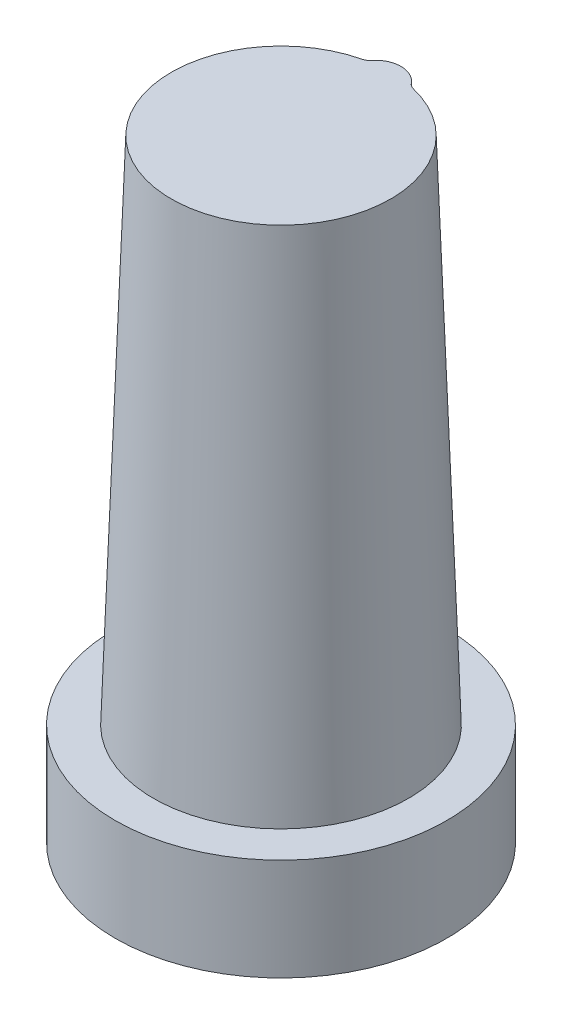
from build123d import *

# Parameters (mm, degrees)
SKIZZE1_R                       = 25
AUFSATZ_LINEAR_AUSTRAGEN1_DEPTH = 100
SKIZZE2_R                       = 32.5
AUFSATZ_LINEAR_AUSTRAGEN2_DEPTH = 20
FORMSCHR_GE1_ANGLE              = 2
VERRUNDUNG1_R                   = 2


with BuildPart() as part:
    # Skizze1 → Aufsatz-Linear austragen1 (new body)
    with BuildSketch(Plane(origin=(0, 0, 0), x_dir=(1, 0, 0), z_dir=(0, 1, 0))):
        with Locations(Location((0, 0, 0), (0, 0, 270))):  # turned: the seam where the file's is
            Circle(SKIZZE1_R)
    extrude(amount=AUFSATZ_LINEAR_AUSTRAGEN1_DEPTH)

    # Skizze2 → Aufsatz-Linear austragen2 (add)
    with BuildSketch(Plane.XZ):
        with Locations(Location((0, 0, 0), (0, 0, 270))):  # turned: the seam where the file's is
            Circle(SKIZZE2_R)
    extrude(amount=AUFSATZ_LINEAR_AUSTRAGEN2_DEPTH)

    # Formschräge1
    formschr_ge1_faces = [part.faces().sort_by_distance(p)[0] for p in [
        (0, 50, -25),
    ]]
    draft(formschr_ge1_faces, Plane.ZX, FORMSCHR_GE1_ANGLE)

    # Austragung6: sweep along a path in Skizze6
    with BuildLine(Plane(origin=(0, 0, 0), x_dir=(0, 0, -1), z_dir=(1, 0, 0))) as austragung6_path:
        Line((21.507923051, 100), (25, 0))
    # Skizze8 → Austragung6 (sweep)
    with BuildSketch(Plane(origin=(0, 100, 0), x_dir=(1, 0, 0), z_dir=(0, 1, 0))):
        with BuildLine():
            ThreePointArc((4.290296742, 21.075675738), (0, 23.507923051), (-4.290296742, 21.075675738))
            ThreePointArc((-4.290296742, 21.075675738), (0, 21.507923051), (4.290296742, 21.075675738))
        make_face()
    sweep(path=austragung6_path.line)

    # Verrundung1
    verrundung1_edges = [part.edges().sort_by_distance(p)[0] for p in [
        (-4.267773944, 50.000105853, -22.858973285),
        (4.267773944, 50.000105853, -22.858973285),
    ]]
    fillet(verrundung1_edges, radius=VERRUNDUNG1_R)


solid = part.part
